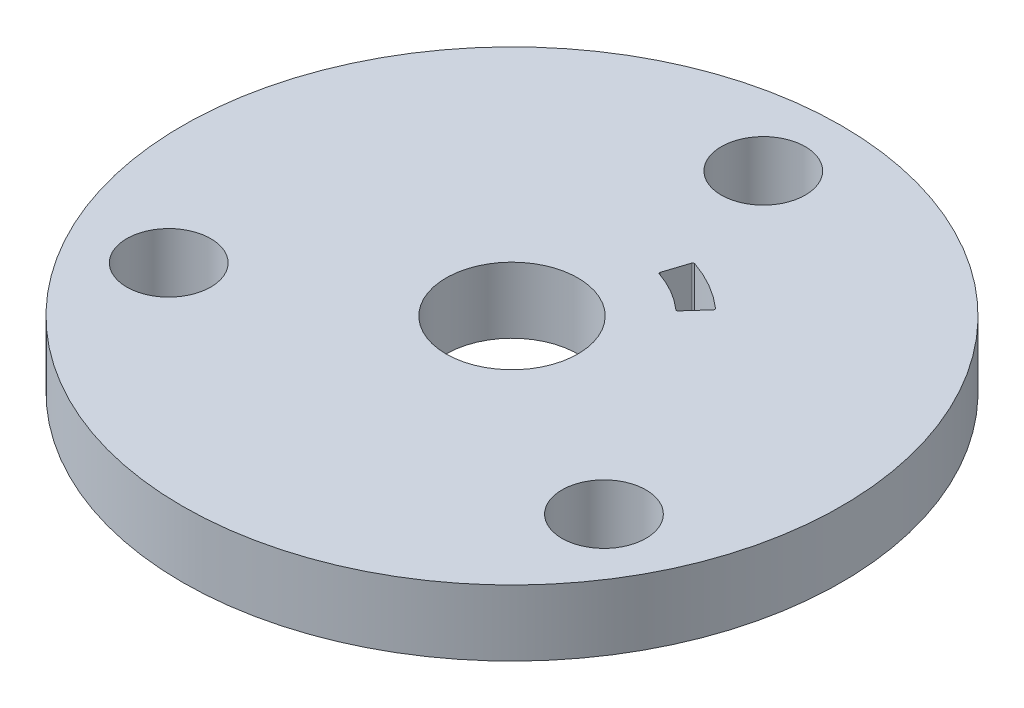
from build123d import *

# Parameters (mm, degrees)
SKETCH1_R           = 20
SKETCH1_R_2         = 4
BOSS_EXTRUDE1_DEPTH = 4
SKETCH2_R           = 2.55
CUT_EXTRUDE2_DEPTH  = 5
CIRPATTERN1_COUNT   = 3
CUT_EXTRUDE3_DEPTH  = 5
FILLET1_R           = 0.1


with BuildPart() as part:
    # Sketch1 → Boss-Extrude1 (new body)
    with BuildSketch(Plane(origin=(0, 0, 0), x_dir=(1, 0, 0), z_dir=(0, 1, 0))):
        Circle(SKETCH1_R)
        Circle(SKETCH1_R_2, mode=Mode.SUBTRACT)
    extrude(amount=BOSS_EXTRUDE1_DEPTH)

    # Sketch2 → Cut-Extrude2 (cut, through all)
    with BuildSketch(Plane(origin=(0, 4, 0), x_dir=(1, 0, 0), z_dir=(0, 1, 0))):
        with Locations((0, 15.25)):
            Circle(SKETCH2_R)
    cut_extrude2 = extrude(amount=-CUT_EXTRUDE2_DEPTH, mode=Mode.SUBTRACT)

    # CirPattern1: Cut-Extrude2 ×3 about axis
    cirpattern1_axis = Axis((0, 0, 0), (0, 1, 0))
    for i in range(1, CIRPATTERN1_COUNT):
        add(cut_extrude2.rotate(cirpattern1_axis, i * 360 / CIRPATTERN1_COUNT), mode=Mode.SUBTRACT)

    # Sketch3 → Cut-Extrude3 (cut, through all)
    with BuildSketch(Plane(origin=(0, 4, 0), x_dir=(1, 0, 0), z_dir=(0, 1, 0))):
        with BuildLine():
            Line((2.703898701, 8.321744518), (2.17856981, 6.70494844))
            ThreePointArc((2.17856981, 6.70494844), (3.525, 6.105479097), (4.717370775, 5.23917102))
            Line((4.717370775, 5.23917102), (5.854892806, 6.502517223))
            ThreePointArc((5.854892806, 6.502517223), (4.375, 7.577722283), (2.703898701, 8.321744518))
        make_face()
    extrude(amount=-CUT_EXTRUDE3_DEPTH, mode=Mode.SUBTRACT)

    # Fillet1
    fillet1_edges = [part.edges().sort_by_distance(p)[0] for p in [
        (2.703898701, 2, -8.321744518),
        (5.854892806, 2, -6.502517223),
        (4.717370775, 2, -5.23917102),
        (2.17856981, 2, -6.70494844),
    ]]
    fillet(fillet1_edges, radius=FILLET1_R)


solid = part.part
